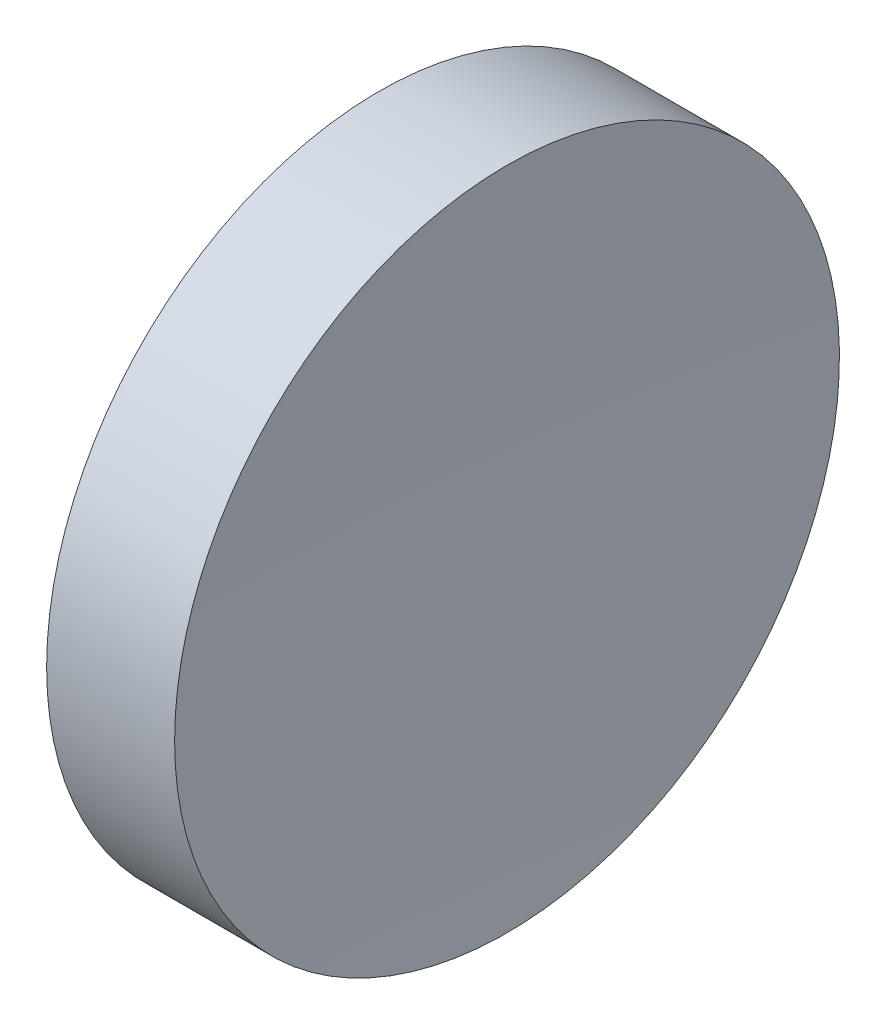
from build123d import *


with BuildPart() as part:
    # 草图1 → 旋转1 (revolve)
    with BuildSketch(Plane.XY):
        with BuildLine():
            Line((230.18531107, 138.756042247), (230.18531107, 163.756042247))
            Line((230.18531107, 163.756042247), (239.810702183, 163.756042247))
            ThreePointArc((239.810702183, 163.756042247), (239.3416833, 151.259952776), (239.185311069, 138.756042247))
            Line((239.185311069, 138.756042247), (230.18531107, 138.756042247))
        make_face()
    revolve(axis=Axis((217.970286004, 138.756042247, 0), (1, 0, 0)))


solid = part.part
